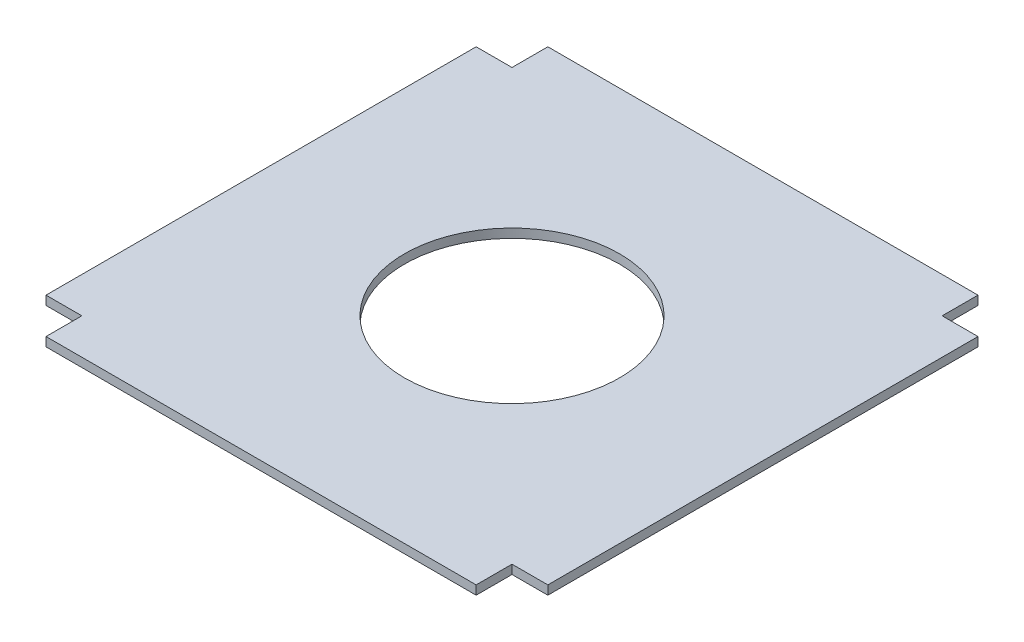
from build123d import *

# Parameters (mm, degrees)
SKETCH1_R           = 76.2
BOSS_EXTRUDE1_DEPTH = 6.35


with BuildPart() as part:
    # Sketch1 → Boss-Extrude1 (new body)
    with BuildSketch(Plane(origin=(0, 0, 0), x_dir=(1, 0, 0), z_dir=(0, 1, 0))):
        Polygon((0, 0), (0, -25.4), (-304.8, -25.4), (-304.8, 0), (-330.2, 0), (-330.2, 304.8), (-304.8, 304.8), (-304.8, 330.2), (0, 330.2), (0, 304.8), (25.4, 304.8), (25.4, 0), align=None)
        with Locations((-152.4, 152.4)):
            Circle(SKETCH1_R, mode=Mode.SUBTRACT)
    extrude(amount=BOSS_EXTRUDE1_DEPTH)


solid = part.part
